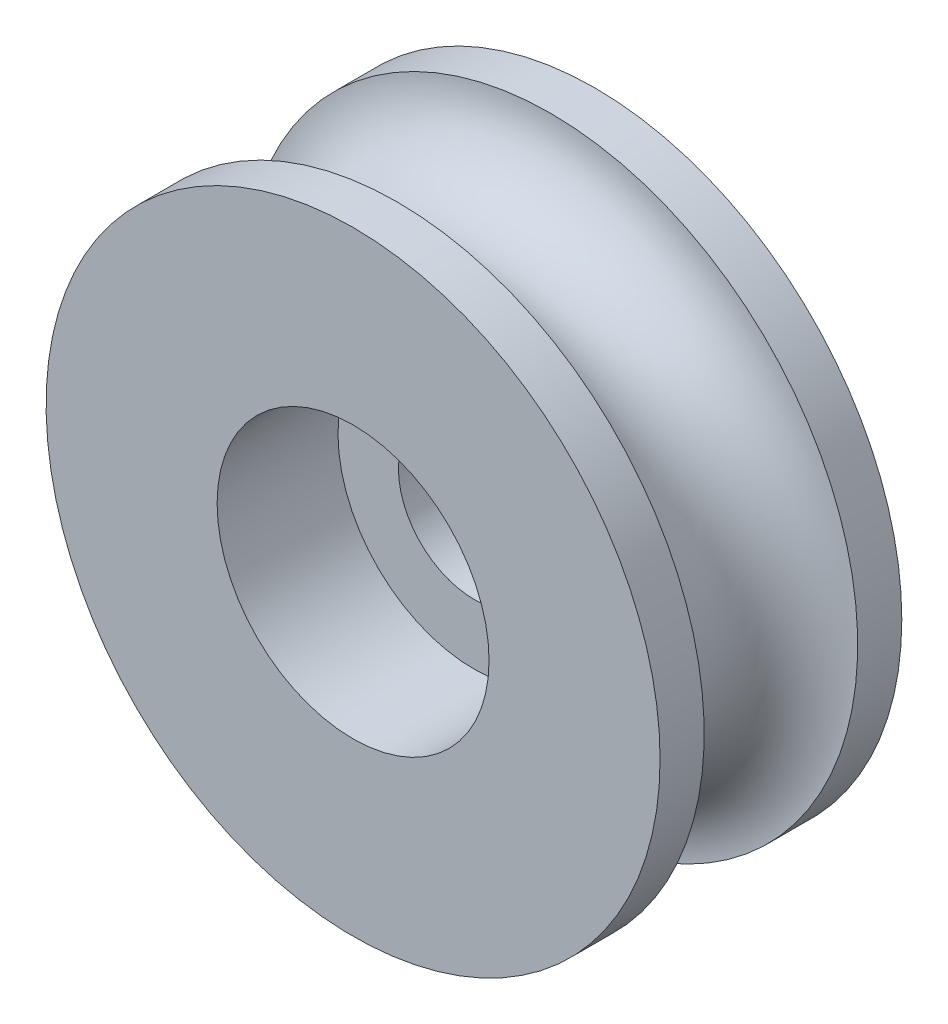
from build123d import *

# Parameters (mm, degrees)
SKETCH1_R           = 10.16
SKETCH1_R_2         = 4.5
BOSS_EXTRUDE1_DEPTH = 8
SKETCH6_R           = 4.5
SKETCH6_R_2         = 2.5
BOSS_EXTRUDE2_DEPTH = 4


with BuildPart() as part:
    # Sketch1 → Boss-Extrude1 (new body)
    with BuildSketch(Plane.XY):
        Circle(SKETCH1_R)
        Circle(SKETCH1_R_2, mode=Mode.SUBTRACT)
    extrude(amount=BOSS_EXTRUDE1_DEPTH)

    # Sketch2 → Cut-Revolve1 (revolve, cut)
    with BuildSketch(Plane(origin=(0, 0, 0), x_dir=(0, 0, -1), z_dir=(1, 0, 0))):
        with BuildLine():
            Line((-6.54, 10.16), (-1.46, 10.16))
            ThreePointArc((-1.46, 10.16), (-4, 7.62), (-6.54, 10.16))
        make_face()
    revolve(axis=Axis((0, 0, 0), (0, 0, 1)), mode=Mode.SUBTRACT)

    # Sketch6 → Boss-Extrude2 (add)
    with BuildSketch(Plane(origin=(0, 0, 0), x_dir=(-1, 0, 0), z_dir=(0, 0, -1))):
        Circle(SKETCH6_R)
        Circle(SKETCH6_R_2, mode=Mode.SUBTRACT)
    extrude(amount=-BOSS_EXTRUDE2_DEPTH)


solid = part.part
